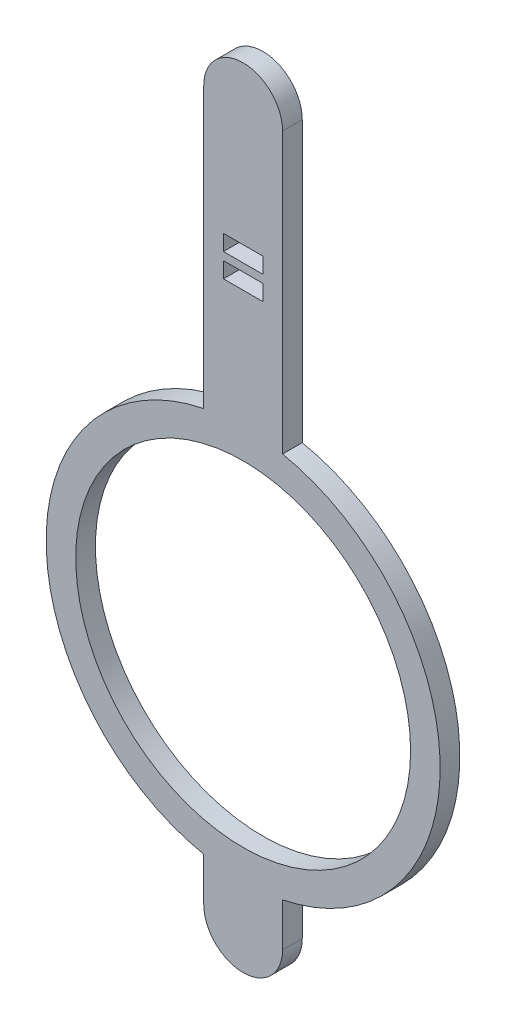
from build123d import *

# Parameters (mm, degrees)
SALIENTE_EXTRUIR1_DEPTH = 0.25
CORTAR_EXTRUIR1_REACH   = 2.25
CROQUIS2_W              = 0.5
CROQUIS2_H              = 0.2


with BuildPart() as part:
    # Croquis1 → Saliente-Extruir1 (new body)
    with BuildSketch(Plane.XY):
        with BuildLine():
            Line((-0.5, -2.449489743), (-0.5, -3))
            ThreePointArc((-0.5, -3), (0, -3.5), (0.5, -3))
            Line((0.5, -3), (0.5, -2.449489743))
            ThreePointArc((0.5, -2.449489743), (2.5, 0), (0.5, 2.449489743))
            Line((0.5, 2.449489743), (0.5, 6))
            ThreePointArc((0.5, 6), (0, 6.5), (-0.5, 6))
            Line((-0.5, 6), (-0.5, 2.449489743))
            ThreePointArc((-0.5, 2.449489743), (-2.5, 0), (-0.5, -2.449489743))
        make_face()
        with BuildLine():
            ThreePointArc((-2.110242877, -0.25), (-1.411448724, -1.588533128), (0, -2.125))
            ThreePointArc((0, -2.125), (1.411448724, -1.588533128), (2.110242877, -0.25))
            ThreePointArc((2.110242877, -0.25), (1.588533128, 1.411448724), (0, 2.125))
            ThreePointArc((0, 2.125), (-1.588533128, 1.411448724), (-2.110242877, -0.25))
        make_face(mode=Mode.SUBTRACT)
    extrude(amount=SALIENTE_EXTRUIR1_DEPTH)

    # Croquis2 → Cortar-Extruir1 (cut, up to next)
    with BuildSketch(Plane(origin=(0, 0, 0), x_dir=(-1, 0, 0), z_dir=(0, 0, -1)), mode=Mode.PRIVATE) as cortar_extruir1_sk1:
        with Locations((0, 4.4)):
            Rectangle(CROQUIS2_W, CROQUIS2_H)
    cortar_extruir1_tool1 = extrude(cortar_extruir1_sk1.sketch, amount=-CORTAR_EXTRUIR1_REACH, mode=Mode.PRIVATE) & part.part
    add(cortar_extruir1_tool1.solids().sort_by_distance((0, 4.4, 0))[0], mode=Mode.SUBTRACT)
    # Croquis2 → Cortar-Extruir1 (cut, up to next)
    with BuildSketch(Plane(origin=(0, 0, 0), x_dir=(-1, 0, 0), z_dir=(0, 0, -1)), mode=Mode.PRIVATE) as cortar_extruir1_sk2:
        with Locations((0, 4.1)):
            Rectangle(CROQUIS2_W, CROQUIS2_H)
    cortar_extruir1_tool2 = extrude(cortar_extruir1_sk2.sketch, amount=-CORTAR_EXTRUIR1_REACH, mode=Mode.PRIVATE) & part.part
    add(cortar_extruir1_tool2.solids().sort_by_distance((0, 4.1, 0))[0], mode=Mode.SUBTRACT)


solid = part.part
